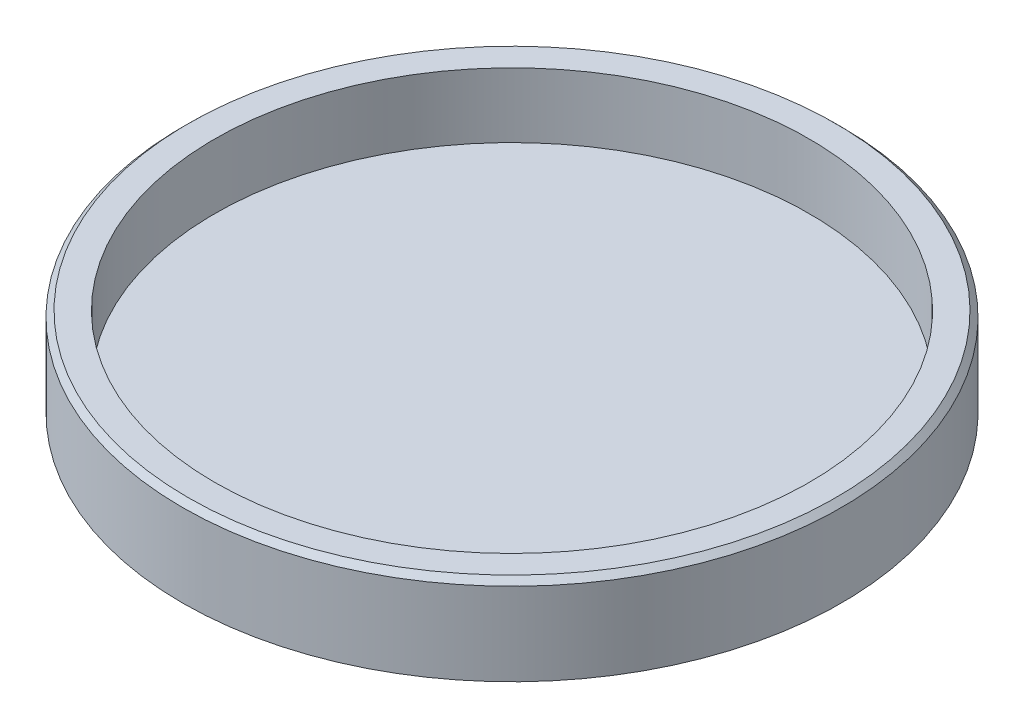
from build123d import *


with BuildPart() as part:
    # Sketch1 → Revolve1 (revolve)
    with BuildSketch(Plane.XY):
        Polygon((0, -1.905027933), (18.5, -1.905027933), (18.5, 2.121725852), (20.146446609, 2.121725852), (20.5, 1.768172462), (20.5, -3.378274148), (0, -3.378274148), align=None)
    revolve(axis=Axis((0, 9.555865922, 0), (0, -1, 0)))


solid = part.part
